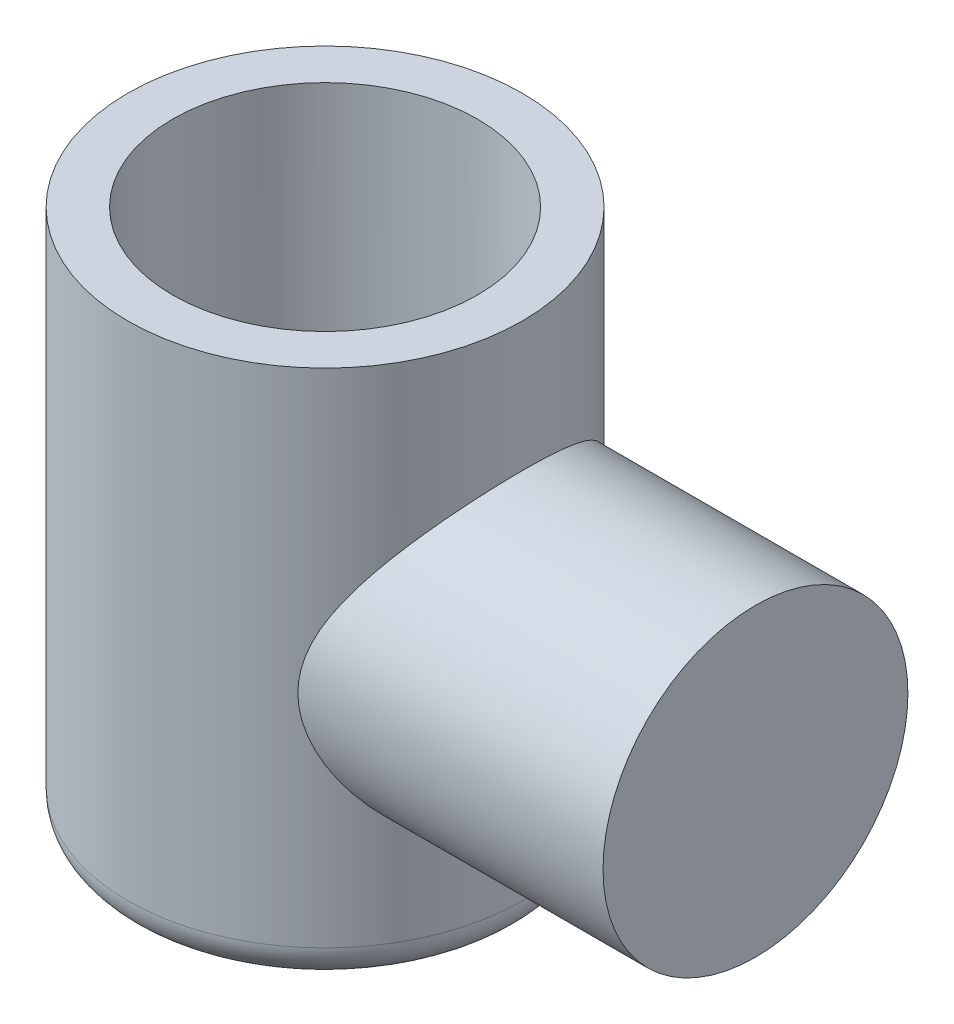
from build123d import *

# Parameters (mm, degrees)
SKETCH1_R           = 55
BOSS_EXTRUDE1_DEPTH = 150
FILLET1_R           = 10
SKETCH3_R           = 42.5
CUT_EXTRUDE2_DEPTH  = 85
SKETCH13_R          = 42.5
BOSS_EXTRUDE3_DEPTH = 120


with BuildPart() as part:
    # Sketch1 → Boss-Extrude1 (new body)
    with BuildSketch(Plane(origin=(0, 0, 0), x_dir=(1, 0, 0), z_dir=(0, 1, 0))):
        Circle(SKETCH1_R)
    extrude(amount=BOSS_EXTRUDE1_DEPTH)

    # Fillet1
    fillet1_edges = [part.edges().sort_by_distance(p)[0] for p in [
        (-55, 0, 0),
    ]]
    fillet(fillet1_edges, radius=FILLET1_R)

    # Sketch3 → Cut-Extrude2 (cut)
    with BuildSketch(Plane(origin=(0, 150, 0), x_dir=(1, 0, 0), z_dir=(0, 1, 0))):
        Circle(SKETCH3_R)
    extrude(amount=-CUT_EXTRUDE2_DEPTH, mode=Mode.SUBTRACT)

    # Sketch13 → Boss-Extrude3 (add)
    with BuildSketch(Plane(origin=(0, 0, 0), x_dir=(0, 0, -1), z_dir=(1, 0, 0))):
        with Locations((0, 71.359942757)):
            Circle(SKETCH13_R)
    extrude(amount=BOSS_EXTRUDE3_DEPTH)


solid = part.part
